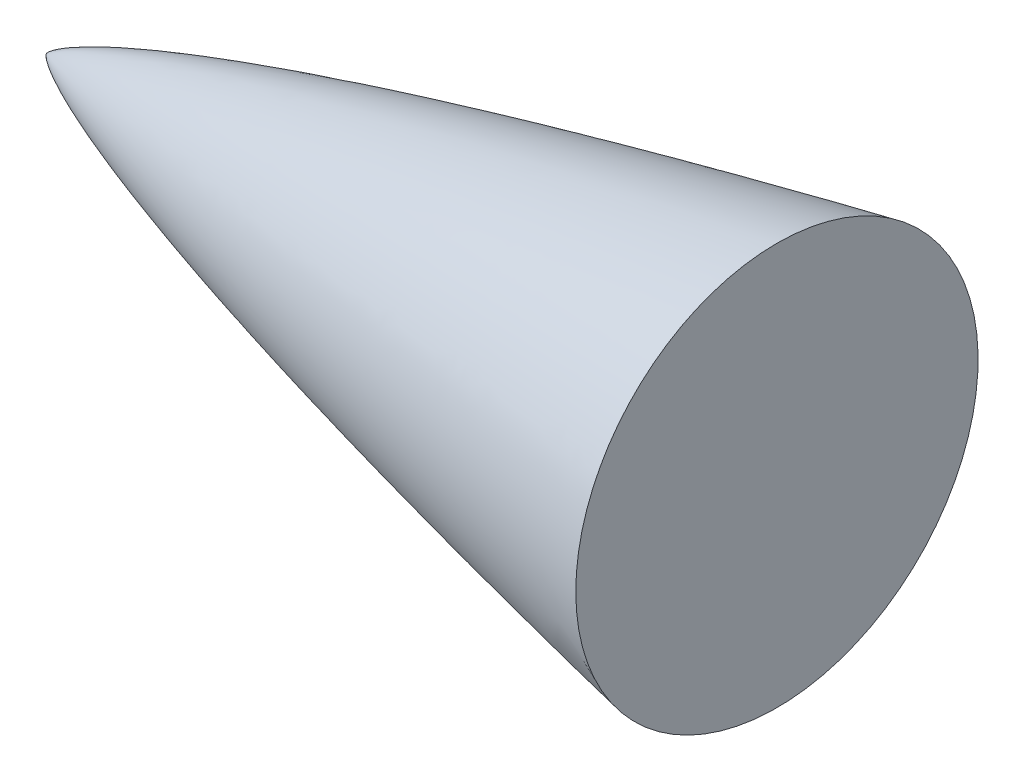
from build123d import *


with BuildPart() as part:
    # Sketch1 → Revolve1 (revolve)
    with BuildSketch(Plane.XY):
        with BuildLine():
            Line((0, 0), (44.45, 0))
            Line((44.45, 0), (44.45, 12.240378041))
            add(Edge.make_bspline(
                [(0, 0), (0.003011993, 0.009762905), (0.010551133, 0.02627483), (0.02586653, 0.047678002), (0.049584294, 0.077338244), (0.081109462, 0.111493124), (0.128401712, 0.157512982), (0.205163795, 0.22377356), (0.332159509, 0.321448772), (0.544576149, 0.465759826), (0.901635526, 0.680174208), (1.511388987, 1.001718774), (2.462796137, 1.442793313), (4.09295059, 2.111247407), (6.381601098, 2.935896342), (9.2264135, 3.855300668), (12.493682634, 4.822076041), (15.835168377, 5.74326247), (19.15770136, 6.611100285), (22.540430849, 7.451044456), (25.848575151, 8.242583043), (29.298149728, 9.033648458), (32.531227192, 9.756334274), (36.13463826, 10.530595732), (39.137485197, 11.164854423), (42.141706028, 11.776943106), (43.678800663, 12.086444554), (44.45, 12.240378041)],
                knots=[0, 0, 0, 0, 0, 0.000801269, 0.001433793, 0.002050484, 0.002997487, 0.004453093, 0.006630366, 0.010023953, 0.015611291, 0.024645739, 0.039425352, 0.064225022, 0.098209944, 0.163173804, 0.23114372, 0.299113647, 0.36708357, 0.435053499, 0.503023422, 0.570993349, 0.638963275, 0.7069332, 0.774903126, 0.842873051, 0.910842976, 0.910842976, 0.910842976, 0.910842976, 0.910842976], degree=4))
        make_face()
    revolve(axis=Axis((0, 0, 0), (1, 0, 0)))


solid = part.part
